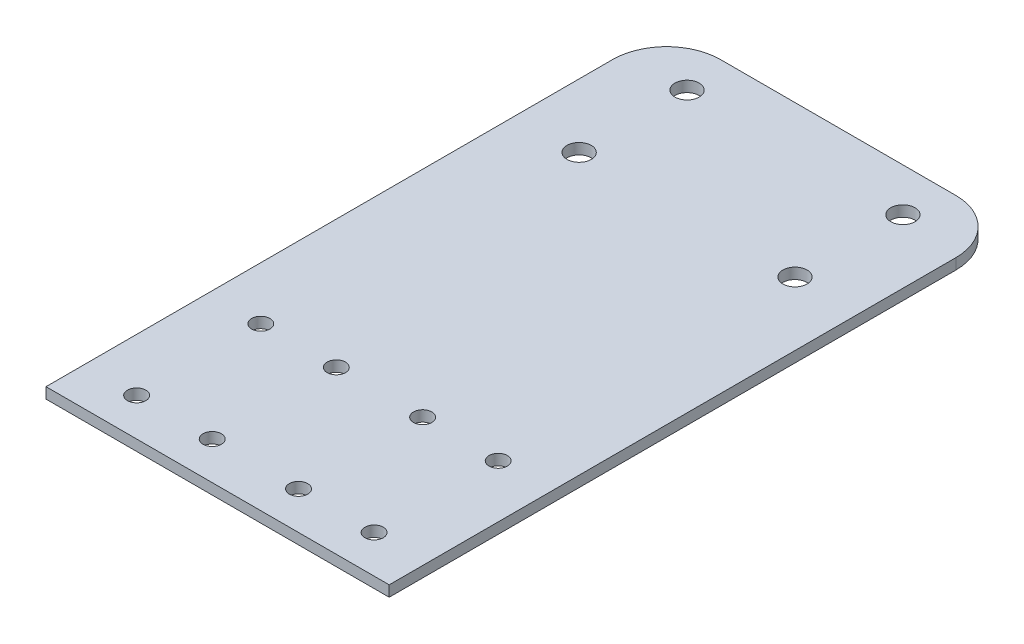
from build123d import *

# Parameters (mm, degrees)
SHEET_EXTRUDE_DEPTH      = 31.8
M3_CLEARANCE_HOLE1_D     = 3.4
M3_CLEARANCE_HOLE1_DEPTH = 8.5
M3_CLEARANCE_HOLE1_TIP   = 1.021463052
M4_CLEARANCE_HOLE1_D     = 4.5
M4_CLEARANCE_HOLE1_DEPTH = 8.5
M4_CLEARANCE_HOLE1_TIP   = 1.351936393
FILLET1_R                = 10


with BuildPart() as part:
    # Sketch2 → Sheet Extrude (new body, symmetric)
    with BuildSketch(Plane(origin=(0, 0, 0), x_dir=(0, 0, -1), z_dir=(1, 0, 0))):
        Polygon((0, 0), (0, 2), (-35, 2), (-55, 2), (-115, 2), (-115, 0), (-55, 0), (-35, 0), align=None)
    extrude(amount=SHEET_EXTRUDE_DEPTH, both=True)

    # M3 Clearance Hole1
    with Locations(Plane(origin=(0, 2, 0), x_dir=(1, 0, 0), z_dir=(0, 1, 0))):
        with Locations((-22, -108), (-22, -85), (-8, -85), (-8, -108), (22, -108), (8, -108), (8, -85), (22, -85)):
            Hole(M3_CLEARANCE_HOLE1_D / 2, depth=M3_CLEARANCE_HOLE1_DEPTH)
            with Locations((0, 0, -(M3_CLEARANCE_HOLE1_DEPTH + M3_CLEARANCE_HOLE1_TIP / 2))):  # 118° drill point
                Cone(0, M3_CLEARANCE_HOLE1_D / 2, M3_CLEARANCE_HOLE1_TIP, mode=Mode.SUBTRACT)

    # M4 Clearance Hole1
    with Locations(Plane(origin=(0, 2, 0), x_dir=(1, 0, 0), z_dir=(0, 1, 0))):
        with Locations((-20, -28), (20, -28), (20, -8), (-20, -8)):
            Hole(M4_CLEARANCE_HOLE1_D / 2, depth=M4_CLEARANCE_HOLE1_DEPTH)
            with Locations((0, 0, -(M4_CLEARANCE_HOLE1_DEPTH + M4_CLEARANCE_HOLE1_TIP / 2))):  # 118° drill point
                Cone(0, M4_CLEARANCE_HOLE1_D / 2, M4_CLEARANCE_HOLE1_TIP, mode=Mode.SUBTRACT)

    # Fillet1
    fillet1_edges = [part.edges().sort_by_distance(p)[0] for p in [
        (-31.8, 1, 0),
        (31.8, 1, 0),
    ]]
    fillet(fillet1_edges, radius=FILLET1_R)


solid = part.part
